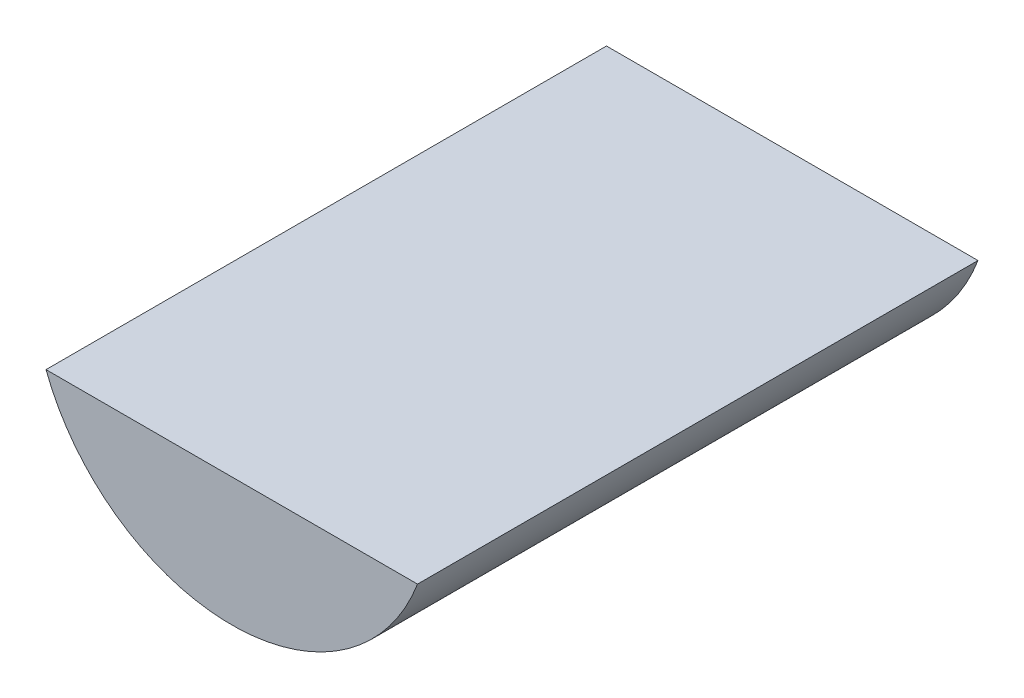
from build123d import *

# Parameters (mm, degrees)
BOSS_EXTRUDE1_DEPTH = 1092.2
BOSS_EXTRUDE2_DEPTH = 17.78
LPATTERN1_COUNT     = 5
LPATTERN1_PITCH     = 1092.2


with BuildPart() as part:
    # Sketch3 → Boss-Extrude1 (new body)
    with BuildSketch(Plane.XY.offset(-4572)):
        with BuildLine():
            ThreePointArc((-1809.906403768, -685.8), (0, -1935.48), (1809.906403768, -685.8))
            Line((1809.906403768, -685.8), (-1809.906403768, -685.8))
        make_face()
        Polygon((-1193.8, -1384.3), (-1193.8, -762), (1193.8, -762), (1193.8, -1384.3), (577.85, -1790.7), (-577.85, -1790.7), align=None, mode=Mode.SUBTRACT)
    boss_extrude1 = extrude(amount=-BOSS_EXTRUDE1_DEPTH)

    # Sketch3_4 → Boss-Extrude2 (add)
    with BuildSketch(Plane.XY.offset(-4572)):
        with BuildLine():
            ThreePointArc((-1809.906403768, -685.8), (0, -1935.48), (1809.906403768, -685.8))
            Line((1809.906403768, -685.8), (-1809.906403768, -685.8))
        make_face()
    boss_extrude2 = extrude(amount=-BOSS_EXTRUDE2_DEPTH)

    # LPattern1: Boss-Extrude1, Boss-Extrude2 ×5
    with Locations(*[(0, 0, -i * LPATTERN1_PITCH) for i in range(1, LPATTERN1_COUNT)]):
        add(boss_extrude1)
        add(boss_extrude2)


with BuildPart() as part_1:
    # Body-Move_Copy1: moved
    add(part.part.moved(Location((0, 76.2, 0))))


solid = part_1.part
